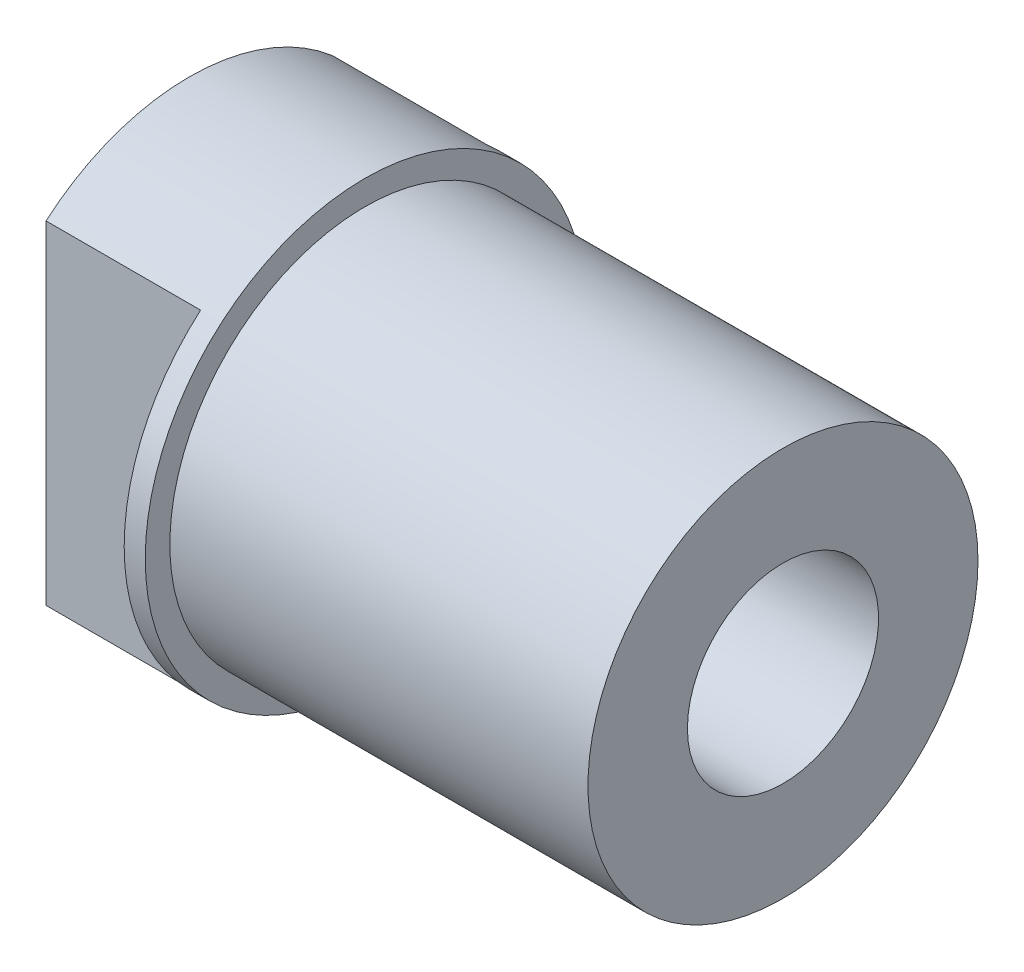
from build123d import *

# Parameters (mm, degrees)
SKETCH2_R                = 7.9375
BOSS_EXTRUDE1_DEPTH      = 6.35
SKETCH3_R                = 7.0485
BOSS_EXTRUDE2_DEPTH      = 15.113
SKETCH4_W                = 5.588
SKETCH4_H                = 2.76225
CUT_EXTRUDE1_DEPTH       = 6.35
F_5_16_24_TAPPED_HOLE1_D = 6.9088


with BuildPart() as part:
    # Sketch2 → Boss-Extrude1 (new body)
    with BuildSketch(Plane(origin=(0, 0, 0), x_dir=(0, 0, -1), z_dir=(1, 0, 0))):
        Circle(SKETCH2_R)
    extrude(amount=-BOSS_EXTRUDE1_DEPTH)

    # Sketch3 → Boss-Extrude2 (add)
    with BuildSketch(Plane(origin=(0, 0, 0), x_dir=(0, 0, -1), z_dir=(1, 0, 0))):
        Circle(SKETCH3_R)
    extrude(amount=BOSS_EXTRUDE2_DEPTH)

    # Sketch4 → Cut-Extrude1 (cut, symmetric)
    with BuildSketch(Plane(origin=(0, 0, 0), x_dir=(1, 0, 0), z_dir=(0, 1, 0))):
        with Locations((-3.556, 6.556375)):
            Rectangle(SKETCH4_W, SKETCH4_H)
        with Locations((-3.556, -6.556375)):
            Rectangle(SKETCH4_W, SKETCH4_H)
    extrude(amount=CUT_EXTRUDE1_DEPTH, both=True, mode=Mode.SUBTRACT)

    # 5/16-24 Tapped Hole1 (through all)
    with Locations(Plane(origin=(-6.35, 0, 0), x_dir=(0, 0, -1), z_dir=(-1, 0, 0))):
        with Locations((0, 0)):
            Hole(F_5_16_24_TAPPED_HOLE1_D / 2)


solid = part.part
